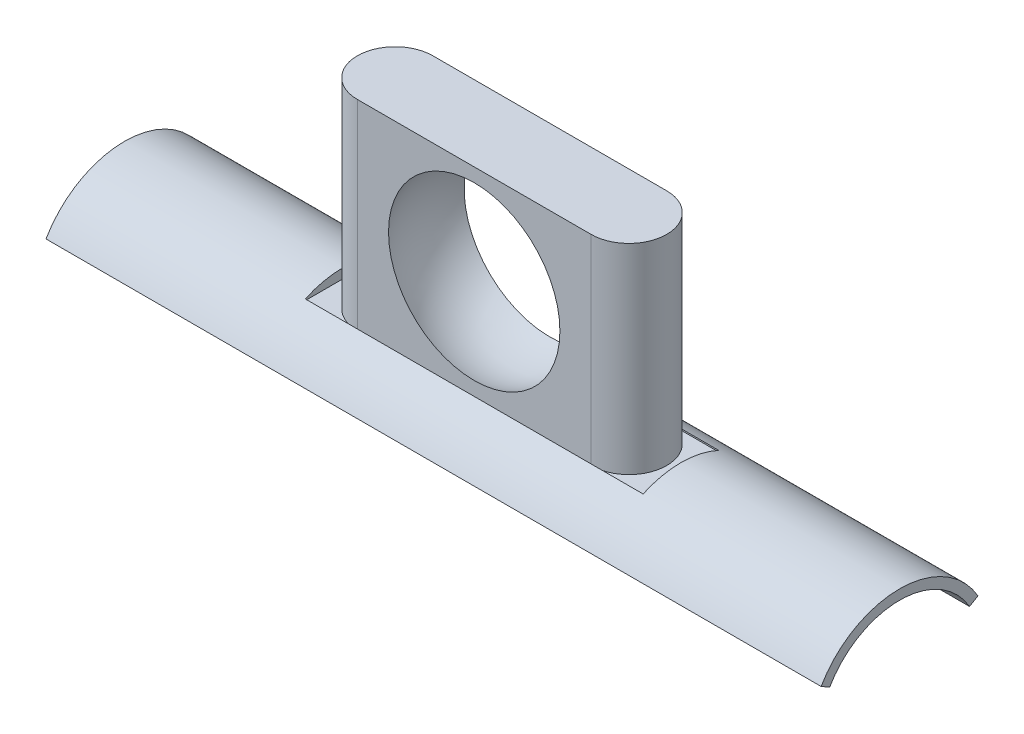
from build123d import *

# Parameters (mm, degrees)
BOSS_EXTRUDE2_DEPTH = 152.4
SKETCH6_W           = 132.842
SKETCH6_H           = 29.718
CUT_EXTRUDE1_DEPTH  = 3.81
BOSS_EXTRUDE3_DEPTH = 78.74


with BuildPart() as part:
    # Sketch3 → Boss-Extrude2 (new body, symmetric)
    with BuildSketch(Plane(origin=(0, 0, 0), x_dir=(0, 0, -1), z_dir=(1, 0, 0))):
        with BuildLine():
            Line((-27.49630657, 15.875), (-30.850855972, 17.81175))
            ThreePointArc((-30.850855972, 17.81175), (0, 35.6235), (30.850855972, 17.81175))
            Line((30.850855972, 17.81175), (27.49630657, 15.875))
            ThreePointArc((27.49630657, 15.875), (0, 31.75), (-27.49630657, 15.875))
        make_face()
    extrude(amount=BOSS_EXTRUDE2_DEPTH, both=True)

    # Sketch6 → Cut-Extrude1 (cut)
    with BuildSketch(Plane(origin=(0, 35.6235, 0), x_dir=(1, 0, 0), z_dir=(0, 1, 0))):
        Rectangle(SKETCH6_W, SKETCH6_H)
    extrude(amount=-CUT_EXTRUDE1_DEPTH, mode=Mode.SUBTRACT)

    # Sketch8 → Boss-Extrude3 (add)
    with BuildSketch(Plane(origin=(0, 31.8135, 0), x_dir=(1, 0, 0), z_dir=(0, 1, 0))):
        with BuildLine():
            Line((-45.974, 14.859), (45.974, 14.859))
            ThreePointArc((45.974, 14.859), (60.833, 0), (45.974, -14.859))
            Line((45.974, -14.859), (-45.974, -14.859))
            ThreePointArc((-45.974, -14.859), (-60.833, 0), (-45.974, 14.859))
        make_face()
    extrude(amount=BOSS_EXTRUDE3_DEPTH)

    # Sketch9 → Cut-Revolve1 (revolve, cut)
    with BuildSketch(Plane.XY):
        with BuildLine():
            Line((0, 108.322594497), (0, 34.662594497))
            ThreePointArc((0, 34.662594497), (36.83, 71.492594497), (0, 108.322594497))
        make_face()
    revolve(axis=Axis((0, 108.322594497, 0), (0, -1, 0)), mode=Mode.SUBTRACT)


solid = part.part
